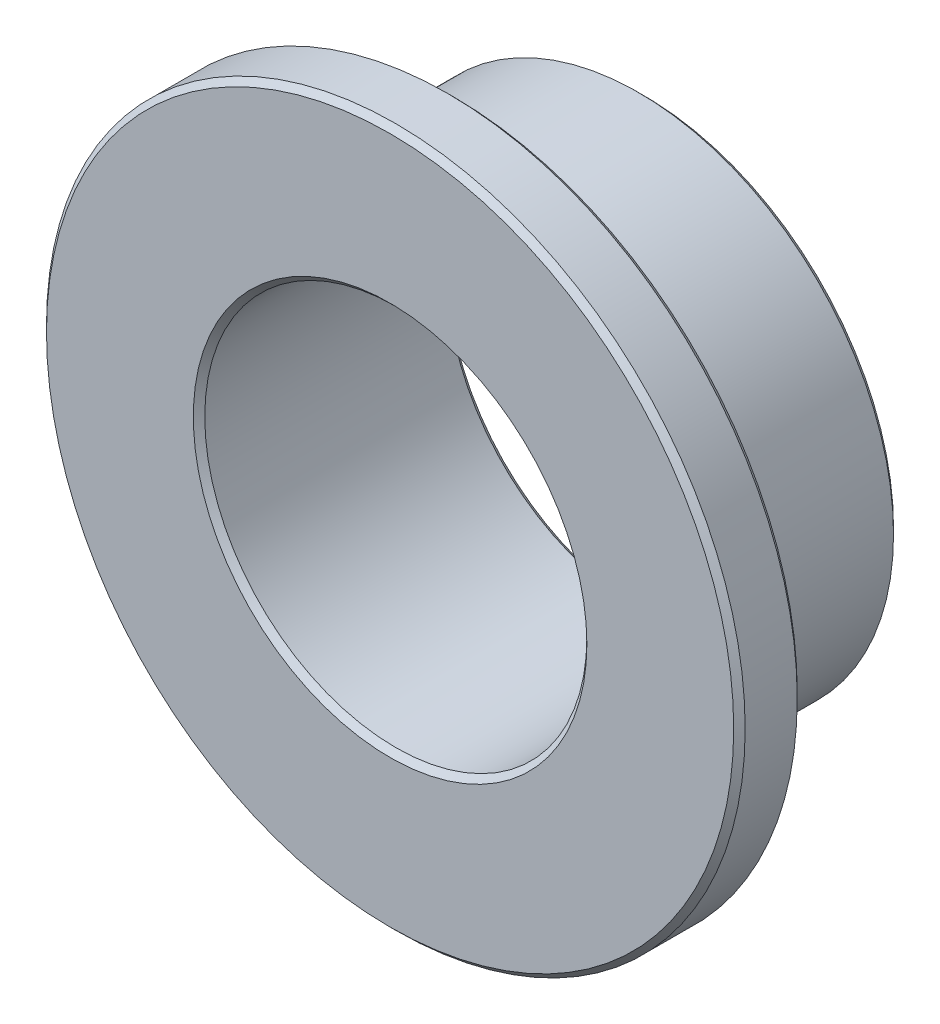
from build123d import *

# Parameters (mm, degrees)
BOSS_EXTRUDE1_START = 3.175
SKETCH3_R           = 8.73125
SKETCH3_R_2         = 4.7752
BOSS_EXTRUDE1_DEPTH = 1.5875
BOSS_EXTRUDE2_START = 1.5875
SKETCH4_R           = 6.3754
SKETCH4_R_2         = 4.7752
BOSS_EXTRUDE2_DEPTH = 4.7625
CHAMFER1_SIZE       = 0.143256


with BuildPart() as part:
    # Sketch3 → Boss-Extrude1 (new body)
    with BuildSketch(Plane.XY.offset(BOSS_EXTRUDE1_START)):
        Circle(SKETCH3_R)
        Circle(SKETCH3_R_2, mode=Mode.SUBTRACT)
    extrude(amount=-BOSS_EXTRUDE1_DEPTH)

    # Sketch4 → Boss-Extrude2 (add)
    with BuildSketch(Plane.XY.offset(BOSS_EXTRUDE2_START)):
        Circle(SKETCH4_R)
        Circle(SKETCH4_R_2, mode=Mode.SUBTRACT)
    extrude(amount=-BOSS_EXTRUDE2_DEPTH)

    # Chamfer1
    chamfer1_edges = [part.edges().sort_by_distance(p)[0] for p in [
        (-4.7752, 0, -3.175),
        (-6.3754, 0, 1.5875),
        (-8.73125, 0, 3.175),
        (-8.73125, 0, 1.5875),
        (-4.7752, 0, 3.175),
        (-6.3754, 0, -3.175),
    ]]
    chamfer(chamfer1_edges, length=CHAMFER1_SIZE)


solid = part.part
